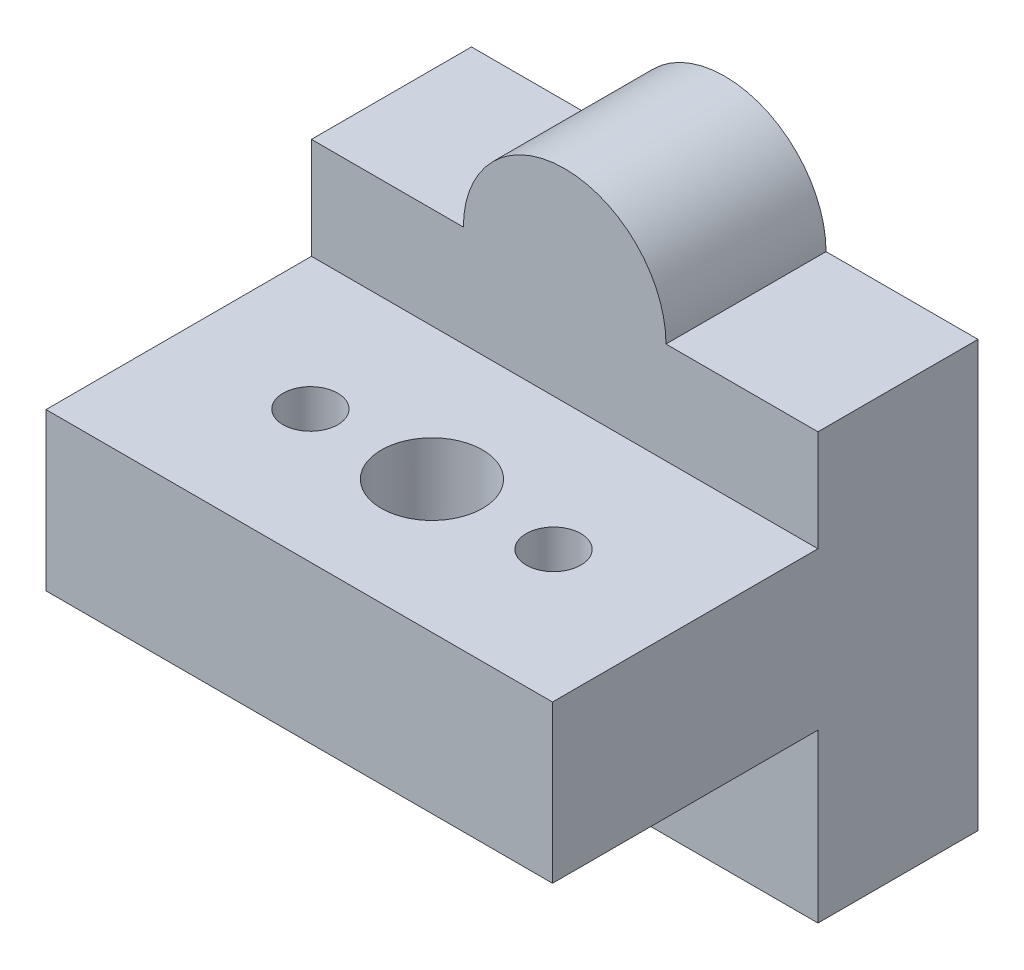
from build123d import *

# Parameters (mm, degrees)
BOSS_EXTRUDE1_DEPTH = 7.9
SKETCH2_W           = 25
SKETCH2_H           = 13.1
SKETCH2_R           = 1.349845
BOSS_EXTRUDE2_DEPTH = 7.75
SKETCH2_4_R         = 2.499995
SKETCH2_4_R_2       = 1.349845
CUT_EXTRUDE1_DEPTH  = 23.498
SKETCH2_6_R         = 2.6999438
SKETCH2_6_R_2       = 1.349845
CUT_EXTRUDE2_DEPTH  = 2.5


with BuildPart() as part:
    # Sketch1 → Boss-Extrude1 (new body)
    with BuildSketch(Plane.XY):
        with BuildLine():
            Line((-5, 10.5), (-12.5, 10.5))
            Line((-12.5, 10.5), (-12.5, -10.5))
            Line((-12.5, -10.5), (12.5, -10.5))
            Line((12.5, -10.5), (12.5, 10.5))
            Line((12.5, 10.5), (5, 10.5))
            ThreePointArc((5, 10.5), (0, 15.5), (-5, 10.5))
        make_face()
    extrude(amount=BOSS_EXTRUDE1_DEPTH)

    # Sketch2 → Boss-Extrude2 (add)
    with BuildSketch(Plane(origin=(0, -2.24999999, 0), x_dir=(1, 0, 0), z_dir=(0, 1, 0))):
        with Locations((0, -14.45)):
            Rectangle(SKETCH2_W, SKETCH2_H)
        with Locations((6.00015, -14.45)):
            Circle(SKETCH2_R, mode=Mode.SUBTRACT)
    extrude(amount=BOSS_EXTRUDE2_DEPTH)

    # Sketch2_4 → Cut-Extrude1 (cut)
    with BuildSketch(Plane(origin=(0, -2.24999999, 0), x_dir=(1, 0, 0), z_dir=(0, 1, 0))):
        with Locations((0, -14.45)):
            Circle(SKETCH2_4_R)
        with Locations((-6.00015, -14.45)):
            Circle(SKETCH2_4_R_2)
    extrude(amount=CUT_EXTRUDE1_DEPTH, mode=Mode.SUBTRACT)

    # Sketch2_6 → Cut-Extrude2 (cut)
    with BuildSketch(Plane(origin=(0, -2.24999999, 0), x_dir=(1, 0, 0), z_dir=(0, 1, 0))):
        with Locations((6.00015, -14.45)):
            Circle(SKETCH2_6_R)
        with Locations((6.00015, -14.45)):
            Circle(SKETCH2_6_R_2, mode=Mode.SUBTRACT)
        with Locations((-6.00015, -14.45)):
            Circle(SKETCH2_6_R)
        with Locations((-6.00015, -14.45)):
            Circle(SKETCH2_6_R_2, mode=Mode.SUBTRACT)
    extrude(amount=CUT_EXTRUDE2_DEPTH, mode=Mode.SUBTRACT)


solid = part.part
